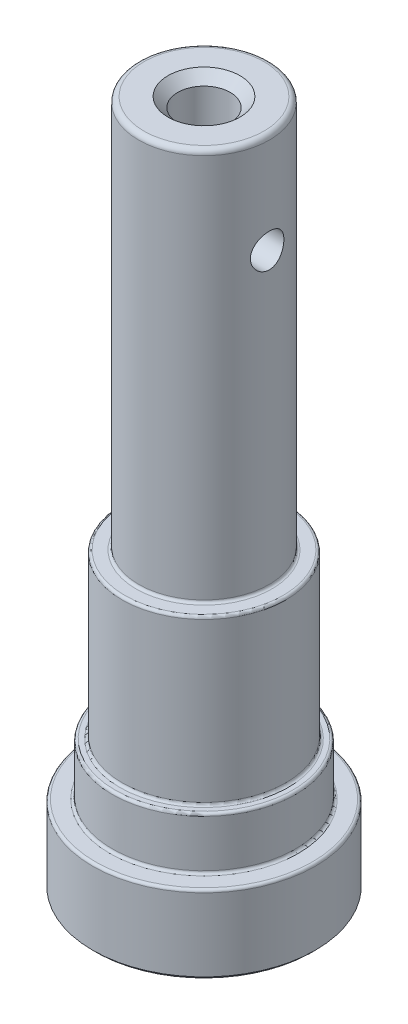
from build123d import *

# Parameters (mm, degrees)
SKETCH1_R                         = 10.795
EXTRUDE1_DEPTH                    = 7.62
SKETCH2_R                         = 8.89
EXTRUDE2_DEPTH                    = 5.08
SKETCH3_R                         = 7.9375
EXTRUDE3_DEPTH                    = 15.875
SKETCH4_R                         = 6.3373
EXTRUDE4_DEPTH                    = 38.1
EXTRUDE5_DEPTH                    = 7.62
F_1_4_20_TAPPED_HOLE1_D           = 5.1054
F_1_4_20_TAPPED_HOLE1_DEPTH       = 13.97
F_1_4_20_TAPPED_HOLE1_CSINK_D     = 6.985
F_1_4_20_TAPPED_HOLE1_CSINK_ANGLE = 90
F_1_4_20_TAPPED_HOLE1_TIP         = 1.533816902
CHAMFER2_SIZE                     = 0.3048
CHAMFER3_SIZE                     = 0.3048
FILLET1_R                         = 0.508
FILLET2_R                         = 0.254
FILLET3_R                         = 0.254
SKETCH10_R                        = 1.6256
EXTRUDE6_DEPTH                    = 11.795
EXTRUDE6_DEPTH_BACK               = 11.795
Y_0_404_DIAMETER_HOLE1_D          = 10.2616
Y_0_404_DIAMETER_HOLE1_DEPTH      = 7.366
Y_0_404_DIAMETER_HOLE1_TIP        = 3.082895664


with BuildPart() as part:
    # Sketch1 → Extrude1 (new body)
    with BuildSketch(Plane(origin=(0, 7.62, 0), x_dir=(-1, 0, 0), z_dir=(0, 1, 0))):
        Circle(SKETCH1_R)
    extrude(amount=-EXTRUDE1_DEPTH)

    # Sketch2 → Extrude2 (add)
    with BuildSketch(Plane(origin=(0, 7.62, 0), x_dir=(-1, 0, 0), z_dir=(0, 1, 0))):
        Circle(SKETCH2_R)
    extrude(amount=EXTRUDE2_DEPTH)

    # Sketch3 → Extrude3 (add)
    with BuildSketch(Plane(origin=(0, 12.7, 0), x_dir=(-1, 0, 0), z_dir=(0, 1, 0))):
        Circle(SKETCH3_R)
    extrude(amount=EXTRUDE3_DEPTH)

    # Sketch4 → Extrude4 (add)
    with BuildSketch(Plane(origin=(0, 28.575, 0), x_dir=(-1, 0, 0), z_dir=(0, 1, 0))):
        Circle(SKETCH4_R)
    extrude(amount=EXTRUDE4_DEPTH)

    # Sketch5 → Extrude5 (cut)
    with BuildSketch(Plane.XZ):
        with BuildLine():
            Line((3.81254, 5.0038), (-3.81254, 5.0038))
            ThreePointArc((-3.81254, 5.0038), (-4.654888024, 4.654888024), (-5.0038, 3.81254))
            Line((-5.0038, 3.81254), (-5.0038, -3.81254))
            ThreePointArc((-5.0038, -3.81254), (-4.654888024, -4.654888024), (-3.81254, -5.0038))
            Line((-3.81254, -5.0038), (3.81254, -5.0038))
            ThreePointArc((3.81254, -5.0038), (4.654888024, -4.654888024), (5.0038, -3.81254))
            Line((5.0038, -3.81254), (5.0038, 3.81254))
            ThreePointArc((5.0038, 3.81254), (4.654888024, 4.654888024), (3.81254, 5.0038))
        make_face()
    extrude(amount=-EXTRUDE5_DEPTH, mode=Mode.SUBTRACT)

    # 1/4-20 Tapped Hole1
    with Locations(Plane(origin=(0, 66.675, 0), x_dir=(-1, 0, 0), z_dir=(0, 1, 0))):
        with Locations((0, 0)):
            CounterSinkHole(F_1_4_20_TAPPED_HOLE1_D / 2, F_1_4_20_TAPPED_HOLE1_CSINK_D / 2, depth=F_1_4_20_TAPPED_HOLE1_DEPTH, counter_sink_angle=F_1_4_20_TAPPED_HOLE1_CSINK_ANGLE)
            with Locations((0, 0, -(F_1_4_20_TAPPED_HOLE1_DEPTH + F_1_4_20_TAPPED_HOLE1_TIP / 2))):  # 118° drill point
                Cone(0, F_1_4_20_TAPPED_HOLE1_D / 2, F_1_4_20_TAPPED_HOLE1_TIP, mode=Mode.SUBTRACT)

    # Chamfer2
    chamfer2_edges = [part.edges().sort_by_distance(p)[0] for p in [
        (4.654888024, 0, 4.654888024),
        (0, 0, 5.0038),
        (-4.654888024, 0, 4.654888024),
        (-5.0038, 0, 0),
        (-4.654888024, 0, -4.654888024),
        (0, 0, -5.0038),
        (4.654888024, 0, -4.654888024),
        (5.0038, 0, 0),
    ]]
    chamfer(chamfer2_edges, length=CHAMFER2_SIZE)

    # Chamfer3
    chamfer3_edges = [part.edges().sort_by_distance(p)[0] for p in [
        (10.795, 0, 0),
    ]]
    chamfer(chamfer3_edges, length=CHAMFER3_SIZE)

    # Fillet1
    fillet1_edges = [part.edges().sort_by_distance(p)[0] for p in [
        (6.3373, 66.675, 0),
    ]]
    fillet(fillet1_edges, radius=FILLET1_R)

    # Fillet2
    fillet2_edges = [part.edges().sort_by_distance(p)[0] for p in [
        (6.3373, 28.575, 0),
        (8.89, 7.62, 0),
        (7.9375, 12.7, 0),
    ]]
    fillet(fillet2_edges, radius=FILLET2_R)

    # Fillet3
    fillet3_edges = [part.edges().sort_by_distance(p)[0] for p in [
        (7.9375, 28.575, 0),
        (10.795, 7.62, 0),
        (8.89, 12.7, 0),
    ]]
    fillet(fillet3_edges, radius=FILLET3_R)

    # Sketch10 → Extrude6 (cut, two sides)
    with BuildSketch(Plane(origin=(0, 0, 0), x_dir=(0, 0, -1), z_dir=(1, 0, 0))) as extrude6_sk:
        with Locations((0, 56.896)):
            Circle(SKETCH10_R)
    extrude(amount=EXTRUDE6_DEPTH, mode=Mode.SUBTRACT)
    extrude(extrude6_sk.sketch, amount=-EXTRUDE6_DEPTH_BACK, mode=Mode.SUBTRACT)

    # Y (0.404) Diameter Hole1
    with Locations(Plane.XZ):
        with Locations((0, 0)):
            Hole(Y_0_404_DIAMETER_HOLE1_D / 2, depth=Y_0_404_DIAMETER_HOLE1_DEPTH)
            with Locations((0, 0, -(Y_0_404_DIAMETER_HOLE1_DEPTH + Y_0_404_DIAMETER_HOLE1_TIP / 2))):  # 118° drill point
                Cone(0, Y_0_404_DIAMETER_HOLE1_D / 2, Y_0_404_DIAMETER_HOLE1_TIP, mode=Mode.SUBTRACT)


solid = part.part
